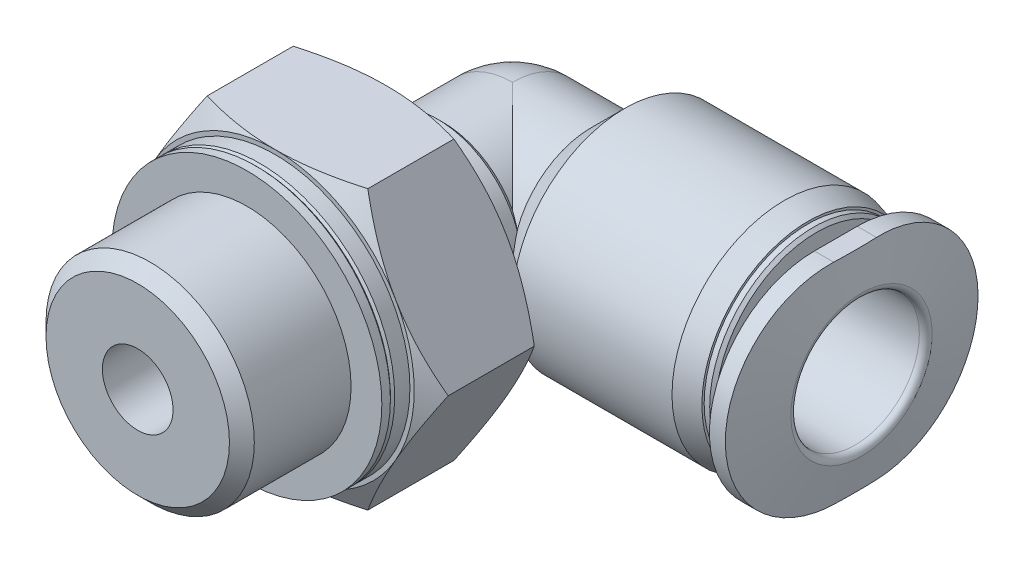
from build123d import *

# Parameters (mm, degrees)
CUT_EXTRUDE1_DEPTH = 1.2
SKETCH6_W          = 17.5
SKETCH6_H          = 1.65
SKETCH7_W          = 26
SKETCH7_H          = 26
CUT_EXTRUDE2_DEPTH = 6.566666667


with BuildPart() as part:
    # Sketch1 → Revolve1 (revolve)
    with BuildSketch(Plane.XY):
        with BuildLine():
            Line((0, 3.675), (3.675, 3.675))
            Line((3.675, 3.675), (5.25, 5.25))
            Line((5.25, 5.25), (12.7, 5.25))
            Line((12.7, 5.25), (13.8, 4.955255888))
            Line((13.8, 4.955255888), (13.8, 4.848076211))
            Line((13.8, 4.848076211), (14.058578644, 4.848076211))
            Line((14.058578644, 4.848076211), (14.2, 4.706654855))
            Line((14.2, 4.706654855), (14.2, 3.5))
            Line((14.2, 3.5), (14.73, 3.5))
            ThreePointArc((14.73, 3.5), (14.991629509, 3.608370491), (15.1, 3.87))
            Line((15.1, 3.87), (15.1, 6.9))
            Line((15.1, 6.9), (15.497402943, 6.9))
            ThreePointArc((15.497402943, 6.9), (15.625960465, 6.853208889), (15.694364494, 6.734729636))
            Line((15.694364494, 6.734729636), (16.3, 3.3))
            Line((16.3, 3.3), (16.3, 0))
            Line((16.3, 0), (-3.675, 0))
            ThreePointArc((-3.675, 0), (-2.598617421, 2.598617421), (0, 3.675))
        make_face()
    revolve(axis=Axis((16.3, 0, 0), (-1, 0, 0)))

    # Sketch2 → Revolve2 (revolve)
    with BuildSketch(Plane(origin=(0, 0, 0), x_dir=(0, 0, -1), z_dir=(1, 0, 0))):
        Polygon((-12.4, 0), (-12.4, 6.3), (-12, 6.3), (-11.9, 6.2), (-11.8, 6.3), (-11.0875, 6.3), (-11.0875, 6.5), (-10.48705572, 7.54), (-6.50669428, 7.54), (-5.90625, 6.5), (-5.90625, 3.9375), (-3.5, 3.9375), (-3.2375, 3.675), (0, 3.675), (0, 0), align=None)
    revolve(axis=Axis((0, 0, 0), (0, 0, 1)))

    # Sketch3 → Revolve3 (revolve)
    with BuildSketch(Plane(origin=(0, 0, 0), x_dir=(0, 0, -1), z_dir=(1, 0, 0))):
        Polygon((-17.5, 0), (-17.5, 4.283), (-16.919, 4.864), (-12.4, 4.864), (-12.4, 0), align=None)
    revolve(axis=Axis((0, 0, 12.4), (0, 0, 1)))

    # Sketch4 → Cut-Extrude1 (cut)
    with BuildSketch(Plane(origin=(16.3, 0, 0), x_dir=(0, 0, -1), z_dir=(1, 0, 0))):
        Polygon((-11.8, -6.812733176), (0, -13.625466353), (11.8, -6.812733176), (11.8, 6.812733176), (0, 13.625466353), (-11.8, 6.812733176), align=None)
        with BuildLine():
            Line((-1, -4.9), (1, -4.9))
            ThreePointArc((1, -4.9), (5.9, 0), (1, 4.9))
            Line((1, 4.9), (-1, 4.9))
            ThreePointArc((-1, 4.9), (-5.9, 0), (-1, -4.9))
        make_face(mode=Mode.SUBTRACT)
    extrude(amount=-CUT_EXTRUDE1_DEPTH, mode=Mode.SUBTRACT)

    # Sketch6 → Cut-Revolve1 (revolve, cut)
    with BuildSketch(Plane(origin=(0, 0, 0), x_dir=(0, 0, -1), z_dir=(1, 0, 0))):
        with Locations((-8.75, 0.825)):
            Rectangle(SKETCH6_W, SKETCH6_H)
    revolve(axis=Axis((0, 0, 0), (0, 0, 1)), mode=Mode.SUBTRACT)

    # Sketch5 → Cut-Revolve2 (revolve, cut)
    with BuildSketch(Plane(origin=(0, 0, 0), x_dir=(1, 0, 0), z_dir=(0, 1, 0))):
        with BuildLine():
            Line((0, 1.65), (4.4, 1.65))
            Line((4.4, 1.65), (4.4, 3))
            Line((4.4, 3), (16, 3))
            ThreePointArc((16, 3), (16.212132034, 3.087867966), (16.3, 3.3))
            Line((16.3, 3.3), (16.3, 0))
            Line((16.3, 0), (-1.65, 0))
            ThreePointArc((-1.65, 0), (-1.166726189, 1.166726189), (0, 1.65))
        make_face()
    revolve(axis=Axis((16.3, 0, 0), (-1, 0, 0)), mode=Mode.SUBTRACT)

    # Sketch7 → Cut-Extrude2 (cut)
    with BuildSketch(Plane.XY.offset(12.4)):
        Rectangle(SKETCH7_W, SKETCH7_H)
        Polygon((-7.505553499, 0), (-3.75277675, -6.5), (3.75277675, -6.5), (7.505553499, 0), (3.75277675, 6.5), (-3.75277675, 6.5), align=None, mode=Mode.SUBTRACT)
    extrude(amount=-CUT_EXTRUDE2_DEPTH, mode=Mode.SUBTRACT)


solid = part.part
